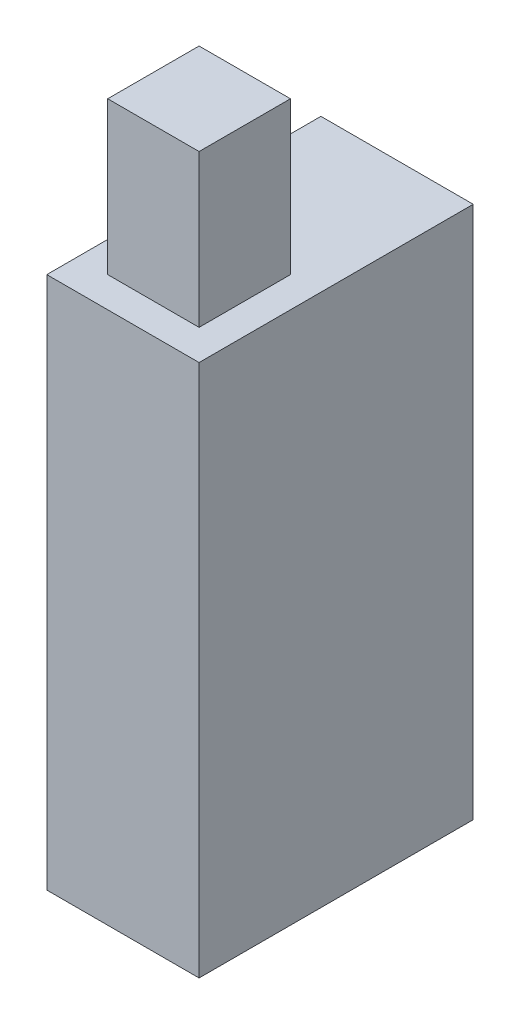
from build123d import *

# Parameters (mm, degrees)
SKETCH1_W           = 20
SKETCH1_H           = 36
BOSS_EXTRUDE1_DEPTH = 70
SKETCH2_W           = 12
SKETCH2_H           = 12
BOSS_EXTRUDE2_DEPTH = 20


with BuildPart() as part:
    # Sketch1 → Boss-Extrude1 (new body)
    with BuildSketch(Plane(origin=(0, 0, 0), x_dir=(1, 0, 0), z_dir=(0, 1, 0))):
        Rectangle(SKETCH1_W, SKETCH1_H)
    extrude(amount=BOSS_EXTRUDE1_DEPTH)

    # Sketch2 → Boss-Extrude2 (add)
    with BuildSketch(Plane(origin=(0, 70, 0), x_dir=(1, 0, 0), z_dir=(0, 1, 0))):
        with Locations((0, -8)):
            Rectangle(SKETCH2_W, SKETCH2_H)
    extrude(amount=BOSS_EXTRUDE2_DEPTH)


solid = part.part
